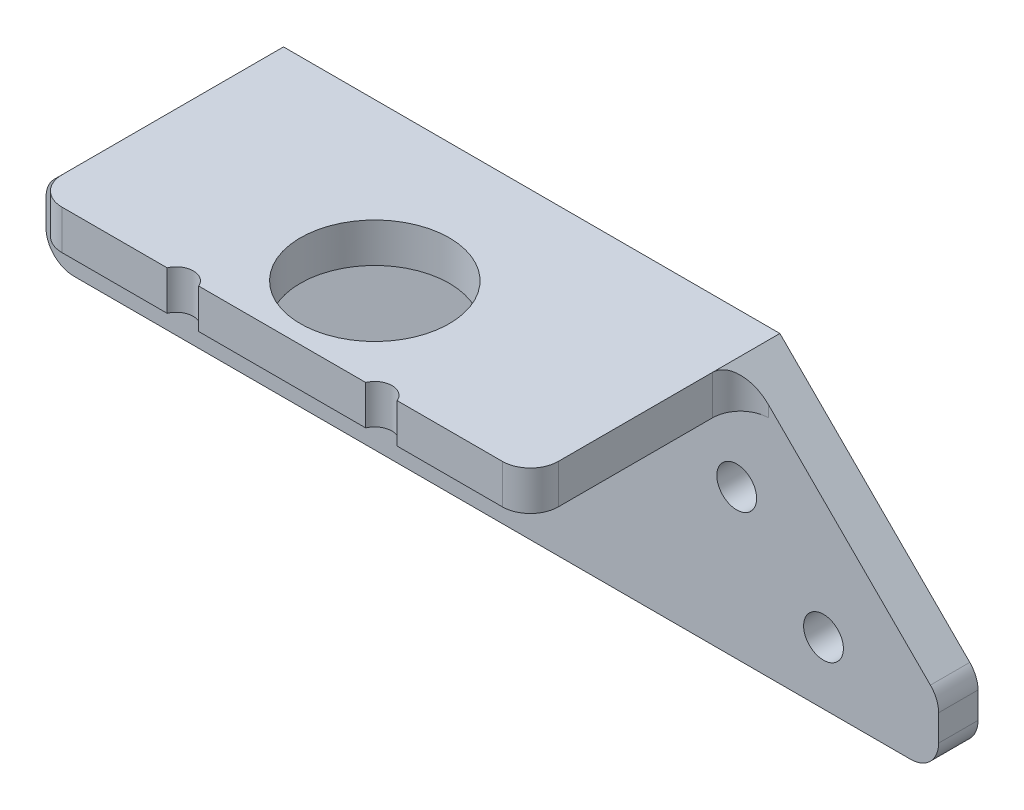
from build123d import *

# Parameters (mm, degrees)
BOSS_EXTRUDE1_DEPTH     = 3.571875
SKETCH2_W               = 45
SKETCH2_H               = 3.571875
BOSS_EXTRUDE2_DEPTH     = 19.05
FILLET1_R               = 2
SKETCH9_W               = 44.9012818
SKETCH9_H               = 1.417156311
CUT_EXTRUDE1_DEPTH      = 10
BOSS_EXTRUDE3_DEPTH     = 3.571875
SKETCH14_R              = 1.8034
CUT_EXTRUDE4_DEPTH      = 4.571875
FILLET3_R               = 2.54
SKETCH15_R              = 6.75
SKETCH15_R_2            = 1.55
CUT_EXTRUDE5_DEPTH      = 21.367363974
CUT_EXTRUDE5_DEPTH_BACK = 4.571875


with BuildPart() as part:
    # Sketch1 → Boss-Extrude1 (new body)
    with BuildSketch(Plane.XY.offset(5)):
        with BuildLine():
            Line((-21.183407813, 0), (-21.183407813, -8.813455393))
            ThreePointArc((-21.183407813, -8.813455393), (-22.866221682, -12.686440931), (-19.530849883, -15.276262248))
            Line((-19.530849883, -15.276262248), (24.68248716, -15.276262248))
            ThreePointArc((24.68248716, -15.276262248), (25.214329472, -14.744419936), (24.68248716, -14.212577623))
            Line((24.68248716, -14.212577623), (23.717873987, 0))
            Line((23.717873987, 0), (23.717873987, 4.989031311))
            Line((23.717873987, 4.989031311), (-21.183407813, 4.989031311))
            Line((-21.183407813, 4.989031311), (-21.183407813, 0))
        make_face()
    extrude(amount=-BOSS_EXTRUDE1_DEPTH)

    # Sketch2 → Boss-Extrude2 (add)
    with BuildSketch(Plane.XY.offset(5)):
        with Locations((1.270019176, 1.7859375)):
            Rectangle(SKETCH2_W, SKETCH2_H)
    extrude(amount=BOSS_EXTRUDE2_DEPTH)

    # Fillet1
    fillet1_edges = [part.edges().sort_by_distance(p)[0] for p in [
        (1.267233087, 4.989031311, 1.428125),
    ]]
    fillet(fillet1_edges, radius=FILLET1_R)

    # Sketch9 → Cut-Extrude1 (cut)
    with BuildSketch(Plane.XY.offset(5)):
        with Locations((1.267233087, 4.280453156)):
            Rectangle(SKETCH9_W, SKETCH9_H)
    extrude(amount=-CUT_EXTRUDE1_DEPTH, mode=Mode.SUBTRACT)

    # Sketch13 → Boss-Extrude3 (add, through all)
    with BuildSketch(Plane.XY.offset(5)):
        Polygon((-21.229980824, 3.571875), (-39.190493066, -14.388637242), (-39.190493066, -20.367363974), (41.730531418, -20.367363974), (41.730531418, -14.388637242), (23.770019176, 3.571875), align=None)
    extrude(amount=-BOSS_EXTRUDE3_DEPTH)

    # Sketch14 → Cut-Extrude4 (cut, through all)
    with BuildSketch(Plane.XY.offset(5)):
        with Locations((-28.755435454, -14.729886975)):
            Circle(SKETCH14_R)
        with Locations((-20.888731092, -6.863182613)):
            Circle(SKETCH14_R)
        with Locations((23.428769443, -6.863182613)):
            Circle(SKETCH14_R)
        with Locations((31.295473805, -14.729886975)):
            Circle(SKETCH14_R)
    extrude(amount=-CUT_EXTRUDE4_DEPTH, mode=Mode.SUBTRACT)

    # Fillet3
    fillet3_edges = [part.edges().sort_by_distance(p)[0] for p in [
        (23.770019176, 1.7859375, 5),
        (-21.229980824, 1.7859375, 5),
        (23.770019176, 1.7859375, 24.05),
        (-21.229980824, 1.7859375, 24.05),
        (41.730531418, -20.367363974, 3.2140625),
        (-39.190493066, -20.367363974, 3.2140625),
        (-39.190493066, -14.388637242, 3.2140625),
        (41.730531418, -14.388637242, 3.2140625),
    ]]
    fillet(fillet3_edges, radius=FILLET3_R)

    # Sketch15 → Cut-Extrude5 (cut, two sides)
    with BuildSketch(Plane.XZ) as cut_extrude5_sk:
        with Locations((1.270019176, 15.652125)):
            Circle(SKETCH15_R)
        with Locations((-7.729980824, 24.652125)):
            Circle(SKETCH15_R_2)
        with Locations((10.270019176, 24.652125)):
            Circle(SKETCH15_R_2)
    extrude(amount=CUT_EXTRUDE5_DEPTH, mode=Mode.SUBTRACT)
    extrude(cut_extrude5_sk.sketch, amount=-CUT_EXTRUDE5_DEPTH_BACK, mode=Mode.SUBTRACT)


solid = part.part
